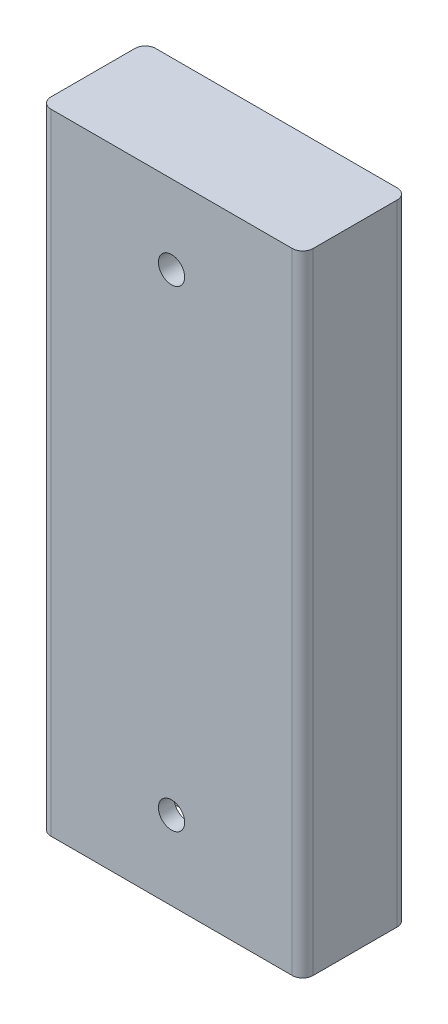
from build123d import *

# Parameters (mm, degrees)
BOSS_EXTRUDE1_DEPTH = 120
SKETCH3_W           = 44
SKETCH3_H           = 14
CUT_EXTRUDE2_DEPTH  = 30
SKETCH6_R           = 2.5
CUT_EXTRUDE3_DEPTH  = 30


with BuildPart() as part:
    # Sketch1 → Boss-Extrude1 (new body)
    with BuildSketch(Plane(origin=(0, 0, 0), x_dir=(1, 0, 0), z_dir=(0, 1, 0))):
        with BuildLine():
            Line((2, 0), (48, 0))
            ThreePointArc((48, 0), (49.414213562, 0.585786438), (50, 2))
            Line((50, 2), (50, 18))
            ThreePointArc((50, 18), (49.414213562, 19.414213562), (48, 20))
            Line((48, 20), (2, 20))
            ThreePointArc((2, 20), (0.585786438, 19.414213562), (0, 18))
            Line((0, 18), (0, 2))
            ThreePointArc((0, 2), (0.585786438, 0.585786438), (2, 0))
        make_face()
    extrude(amount=BOSS_EXTRUDE1_DEPTH)

    # Sketch3 → Cut-Extrude2 (cut)
    with BuildSketch(Plane.XZ):
        with Locations((25, -10)):
            Rectangle(SKETCH3_W, SKETCH3_H)
    extrude(amount=-CUT_EXTRUDE2_DEPTH, mode=Mode.SUBTRACT)

    # Sketch6 → Cut-Extrude3 (cut)
    with BuildSketch(Plane.XY):
        with Locations((25, 105)):
            Circle(SKETCH6_R)
        with Locations((25, 15)):
            Circle(SKETCH6_R)
    extrude(amount=-CUT_EXTRUDE3_DEPTH, mode=Mode.SUBTRACT)


solid = part.part
